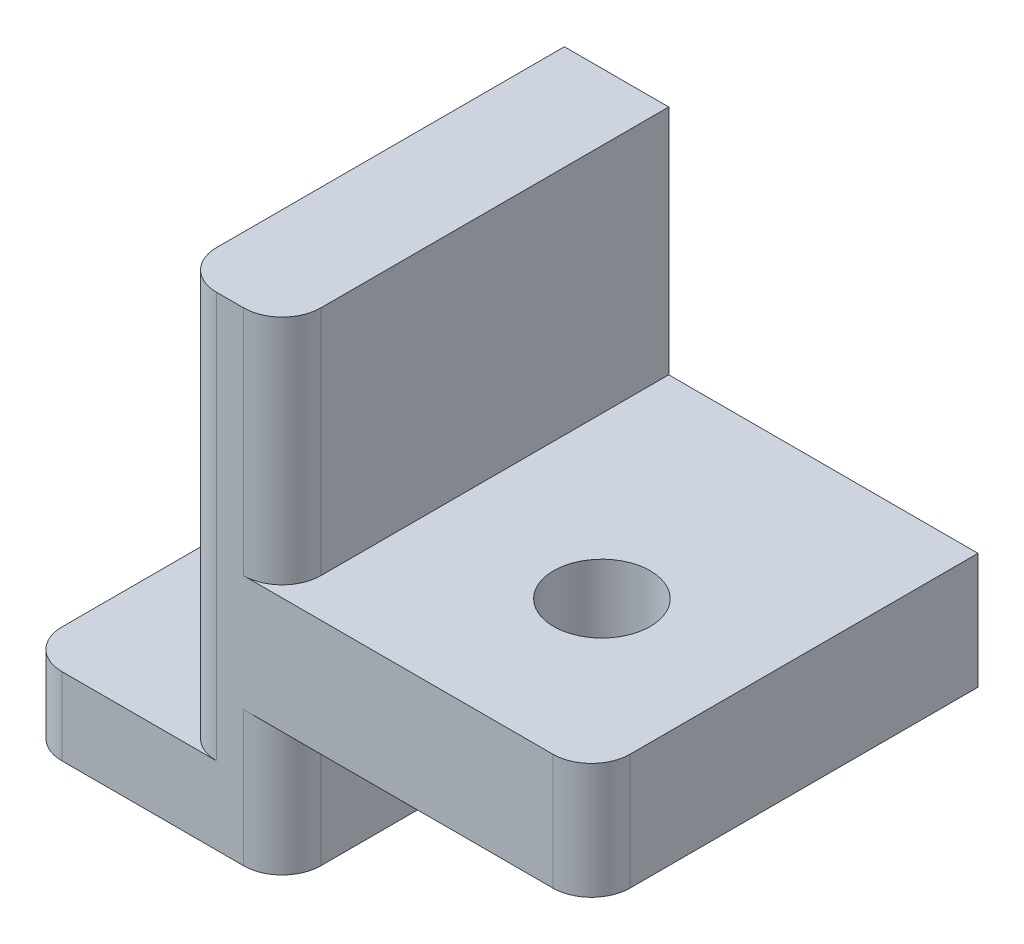
from build123d import *

# Parameters (mm, degrees)
AUFSATZ_LINEAR_AUSTRAGEN1_DEPTH      = 10
F_2_5_2_5_DURCHMESSER_BOHRUNG1_D     = 2.5
F_2_5_2_5_DURCHMESSER_BOHRUNG1_DEPTH = 5
F_2_5_2_5_DURCHMESSER_BOHRUNG1_TIP   = 0.751075774
VERRUNDUNG1_R                        = 1
VERRUNDUNG2_R                        = 1


with BuildPart() as part:
    # Skizze1 → Aufsatz-Linear austragen1 (new body)
    with BuildSketch(Plane.XY):
        Polygon((-2.7, 6), (0, 6), (0, 0), (8, 0), (8, -3), (0, -3), (0, -6.5), (-6.7, -6.5), (-6.7, -4.5), (-2.7, -4.5), align=None)
    extrude(amount=AUFSATZ_LINEAR_AUSTRAGEN1_DEPTH)

    # Ø2.5 (2.5) Durchmesser Bohrung1
    with Locations(Plane(origin=(0, -3, 0), x_dir=(-1, 0, 0), z_dir=(0, -1, 0))):
        with Locations((-4.15, -5.879543152)):
            Hole(F_2_5_2_5_DURCHMESSER_BOHRUNG1_D / 2, depth=F_2_5_2_5_DURCHMESSER_BOHRUNG1_DEPTH)
            with Locations((0, 0, -(F_2_5_2_5_DURCHMESSER_BOHRUNG1_DEPTH + F_2_5_2_5_DURCHMESSER_BOHRUNG1_TIP / 2))):  # 118° drill point
                Cone(0, F_2_5_2_5_DURCHMESSER_BOHRUNG1_D / 2, F_2_5_2_5_DURCHMESSER_BOHRUNG1_TIP, mode=Mode.SUBTRACT)

    # Verrundung1
    verrundung1_edges = [part.edges().sort_by_distance(p)[0] for p in [
        (-6.7, -5.5, 10),
        (0, -4.75, 10),
        (8, -1.5, 10),
        (0, 3, 10),
    ]]
    fillet(verrundung1_edges, radius=VERRUNDUNG1_R)

    # Verrundung2
    verrundung2_edges = [part.edges().sort_by_distance(p)[0] for p in [
        (-2.7, 0.75, 10),
    ]]
    fillet(verrundung2_edges, radius=VERRUNDUNG2_R)


solid = part.part
